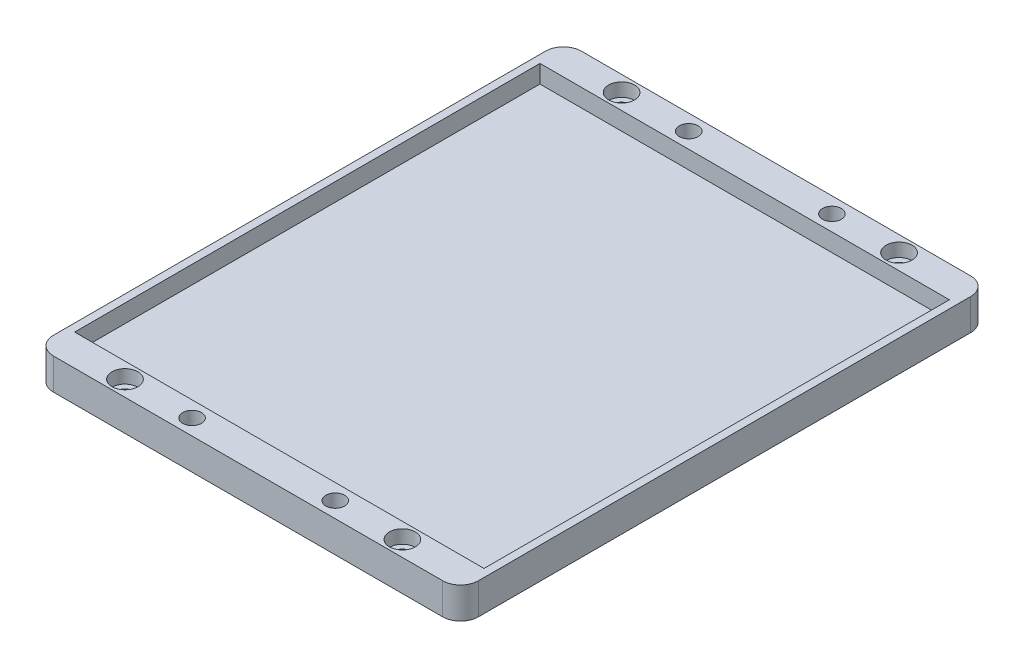
from build123d import *

# Parameters (mm, degrees)
SZKIC1_W                    = 95
SZKIC1_H                    = 118
DODANIE_WYCI_GNI_CIE1_DEPTH = 7
SZKIC2_W                    = 91.5
SZKIC2_H                    = 104
WYTNIJ_WYCI_GNI_CIE1_DEPTH  = 4
SZKIC4_R                    = 1.6
WYTNIJ_WYCI_GNI_CIE3_DEPTH  = 8
ZAOKR_GLENIE1_R             = 4
SZKIC5_R                    = 2.9
WYTNIJ_WYCI_GNI_CIE4_DEPTH  = 3
SZKIC6_R                    = 2.1
WYTNIJ_WYCI_GNI_CIE5_DEPTH  = 6


with BuildPart() as part:
    # Szkic1 → Dodanie-wyciągnięcie1 (new body)
    with BuildSketch(Plane(origin=(0, 0, 0), x_dir=(1, 0, 0), z_dir=(0, 1, 0))):
        Rectangle(SZKIC1_W, SZKIC1_H)
    extrude(amount=DODANIE_WYCI_GNI_CIE1_DEPTH)

    # Szkic2 → Wytnij-wyciągnięcie1 (cut)
    with BuildSketch(Plane(origin=(0, 7, 0), x_dir=(1, 0, 0), z_dir=(0, 1, 0))):
        Rectangle(SZKIC2_W, SZKIC2_H)
    extrude(amount=-WYTNIJ_WYCI_GNI_CIE1_DEPTH, mode=Mode.SUBTRACT)

    # Szkic4 → Wytnij-wyciągnięcie3 (cut, through all)
    with BuildSketch(Plane(origin=(0, 7, 0), x_dir=(1, 0, 0), z_dir=(0, 1, 0))):
        with Locations((31, -55.5)):
            Circle(SZKIC4_R)
        with Locations((-31, -55.5)):
            Circle(SZKIC4_R)
        with Locations((31, 55.5)):
            Circle(SZKIC4_R)
        with Locations((-31, 55.5)):
            Circle(SZKIC4_R)
    extrude(amount=-WYTNIJ_WYCI_GNI_CIE3_DEPTH, mode=Mode.SUBTRACT)

    # Zaokrąglenie1
    zaokr_glenie1_edges = [part.edges().sort_by_distance(p)[0] for p in [
        (47.5, 3.5, 59),
        (-47.5, 3.5, 59),
        (-47.5, 3.5, -59),
        (47.5, 3.5, -59),
    ]]
    fillet(zaokr_glenie1_edges, radius=ZAOKR_GLENIE1_R)

    # Szkic5 → Wytnij-wyciągnięcie4 (cut)
    with BuildSketch(Plane(origin=(0, 7, 0), x_dir=(1, 0, 0), z_dir=(0, 1, 0))):
        with Locations((-31, -55.5)):
            Circle(SZKIC5_R)
        with Locations((-31, 55.5)):
            Circle(SZKIC5_R)
        with Locations((31, -55.5)):
            Circle(SZKIC5_R)
        with Locations((31, 55.5)):
            Circle(SZKIC5_R)
    extrude(amount=-WYTNIJ_WYCI_GNI_CIE4_DEPTH, mode=Mode.SUBTRACT)

    # Szkic6 → Wytnij-wyciągnięcie5 (cut)
    with BuildSketch(Plane(origin=(0, 7, 0), x_dir=(1, 0, 0), z_dir=(0, 1, 0))):
        with Locations((-16, -55.5)):
            Circle(SZKIC6_R)
        with Locations((-16, 55.5)):
            Circle(SZKIC6_R)
        with Locations((16, 55.5)):
            Circle(SZKIC6_R)
        with Locations((16, -55.5)):
            Circle(SZKIC6_R)
    extrude(amount=-WYTNIJ_WYCI_GNI_CIE5_DEPTH, mode=Mode.SUBTRACT)


solid = part.part
